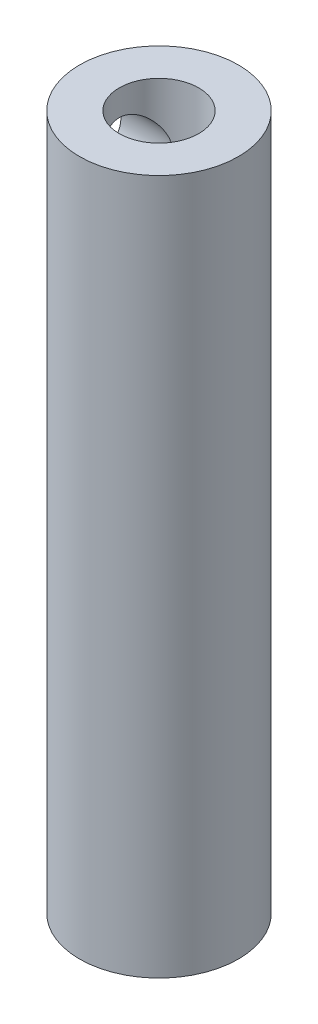
from build123d import *

# Parameters (mm, degrees)
CROQUIS1_R                       = 4
SALIENTE_EXTRUIR1_DEPTH          = 35
CROQUIS2_R                       = 2
CORTAR_EXTRUIR1_DEPTH            = 10
TALADRO_DE_MARGEN_PARA_M31_D     = 3.4
TALADRO_DE_MARGEN_PARA_M31_DEPTH = 3
TALADRO_DE_MARGEN_PARA_M31_TIP   = 1.021463052


with BuildPart() as part:
    # Croquis1 → Saliente-Extruir1 (new body)
    with BuildSketch(Plane(origin=(0, 0, 0), x_dir=(1, 0, 0), z_dir=(0, 1, 0))):
        Circle(CROQUIS1_R)
    extrude(amount=SALIENTE_EXTRUIR1_DEPTH)

    # Croquis2 → Cortar-Extruir1 (cut)
    with BuildSketch(Plane(origin=(0, 35, 0), x_dir=(1, 0, 0), z_dir=(0, 1, 0))):
        Circle(CROQUIS2_R)
    extrude(amount=-CORTAR_EXTRUIR1_DEPTH, mode=Mode.SUBTRACT)

    # Taladro de margen para M31
    with Locations(Plane(origin=(-4, 32, 0), x_dir=(0, 0, -1), z_dir=(-1, 0, 0))):
        with Locations((0, 0)):
            Hole(TALADRO_DE_MARGEN_PARA_M31_D / 2, depth=TALADRO_DE_MARGEN_PARA_M31_DEPTH)
            with Locations((0, 0, -(TALADRO_DE_MARGEN_PARA_M31_DEPTH + TALADRO_DE_MARGEN_PARA_M31_TIP / 2))):  # 118° drill point
                Cone(0, TALADRO_DE_MARGEN_PARA_M31_D / 2, TALADRO_DE_MARGEN_PARA_M31_TIP, mode=Mode.SUBTRACT)


solid = part.part
